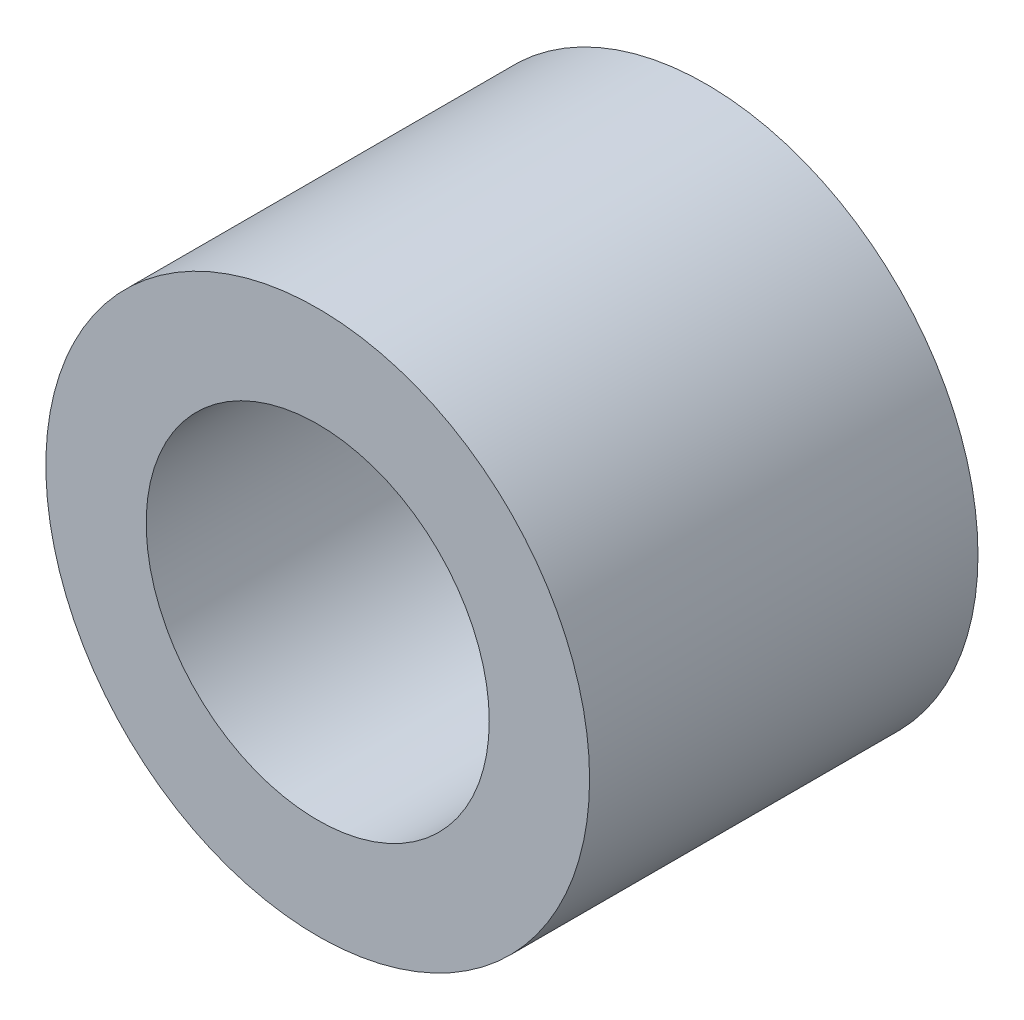
from build123d import *

# Parameters (mm, degrees)
SKETCH_7_W      = 3
SKETCH_7_H      = 1.9
M3X0_351_D      = 2.65
SKETCH_48_R     = 2.1
SKETCH_48_R_2   = 1.9
EXTRUDE_1_DEPTH = 3


with BuildPart() as part:
    # Эскиз7 → Повернуть1 (revolve)
    with BuildSketch(Plane(origin=(0, 0, 0), x_dir=(0, 0, -1), z_dir=(1, 0, 0))):
        with Locations((1.5, 0.95)):
            Rectangle(SKETCH_7_W, SKETCH_7_H)
    revolve(axis=Axis((0, 0, 0), (0, 0, -1)))

    # Отверстие обработанное метчиком M3x0.351 (through all)
    with Locations(Plane.XY):
        with Locations((0, 0)):
            Hole(M3X0_351_D / 2)

    # Эскиз48 → Бобышка-Вытянуть1 (add)
    with BuildSketch(Plane.XY):
        Circle(SKETCH_48_R)
        Circle(SKETCH_48_R_2, mode=Mode.SUBTRACT)
    extrude(amount=-EXTRUDE_1_DEPTH)


solid = part.part
